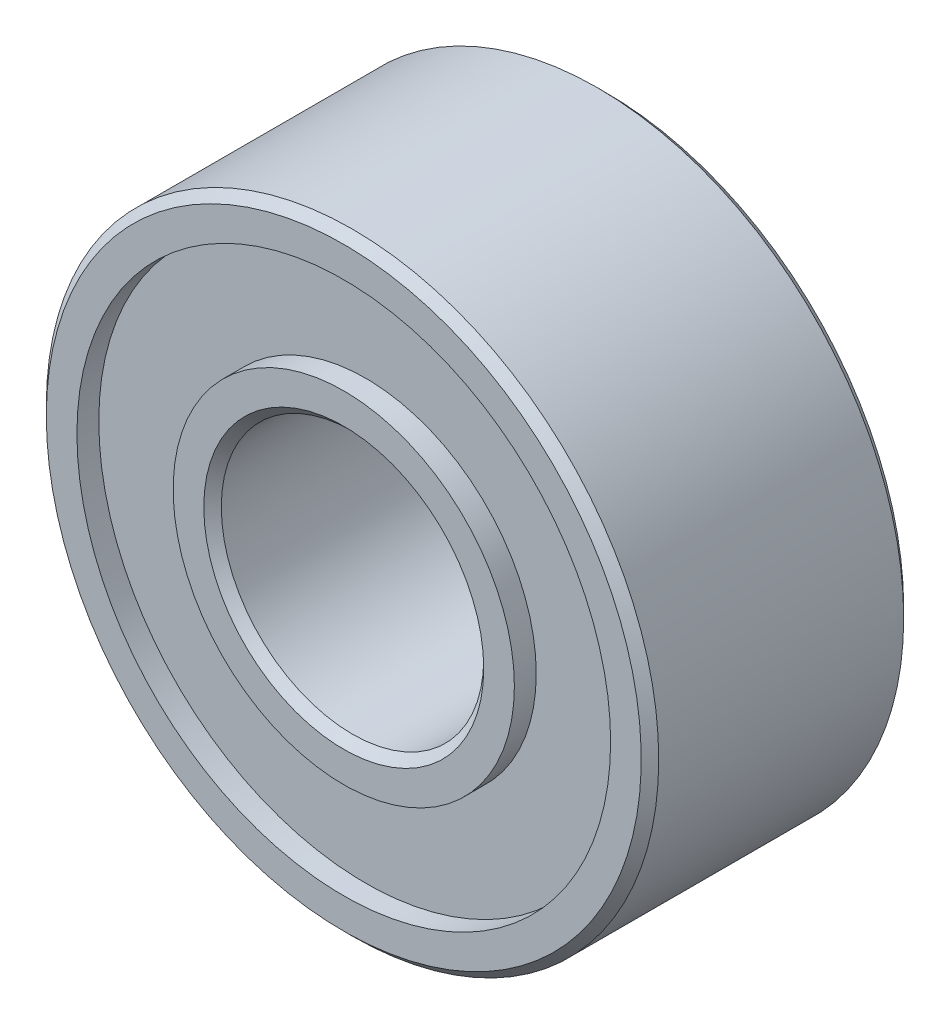
from build123d import *

# Parameters (mm, degrees)
FASE1_SIZE = 0.1


with BuildPart() as part:
    # Skizze2 → Rotation1 (revolve)
    with BuildSketch(Plane(origin=(0, 0, 0), x_dir=(0, 0, -1), z_dir=(1, 0, 0))):
        Polygon((-1.5, 1.5), (1.5, 1.5), (1.5, 1.95), (1.25, 1.95), (1.25, 3.05), (1.5, 3.05), (1.5, 3.5), (-1.5, 3.5), (-1.5, 3.05), (-1.25, 3.05), (-1.25, 1.95), (-1.5, 1.95), align=None)
    revolve(axis=Axis((0, 0, 11.845846522), (0, 0, -1)))

    # Fase1
    fase1_edges = [part.edges().sort_by_distance(p)[0] for p in [
        (0, -1.5, -1.5),
        (0, -1.5, 1.5),
        (0, -3.5, -1.5),
        (0, -3.5, 1.5),
    ]]
    chamfer(fase1_edges, length=FASE1_SIZE)


solid = part.part
